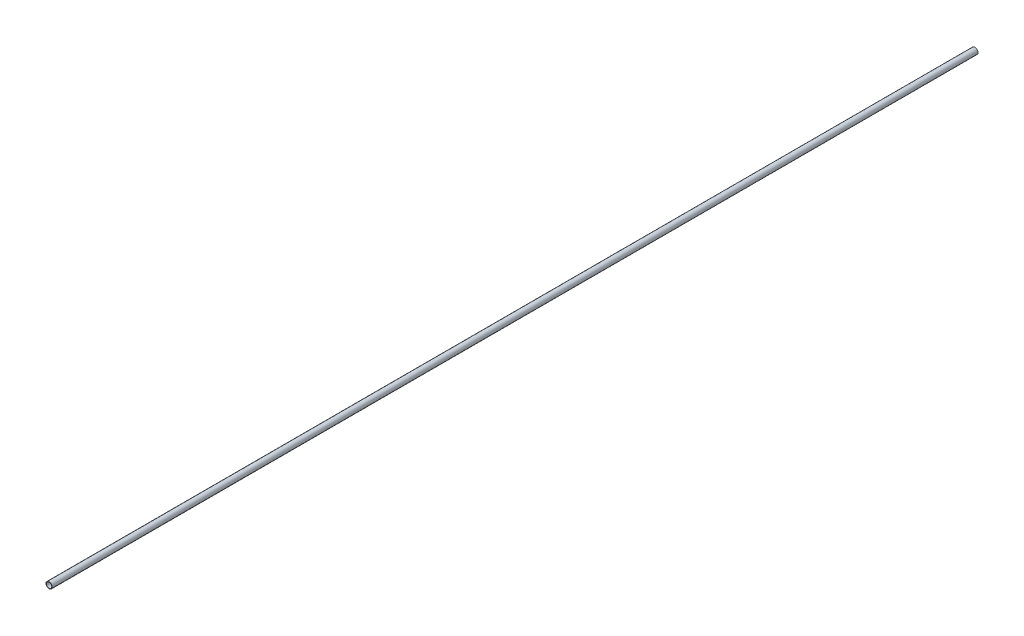
from build123d import *

# Parameters (mm, degrees)
SKETCH1_R           = 4
SKETCH1_R_2         = 3.5
BOSS_EXTRUDE1_DEPTH = 1200


with BuildPart() as part:
    # Sketch1 → Boss-Extrude1 (new body)
    with BuildSketch(Plane.XY):
        Circle(SKETCH1_R)
        Circle(SKETCH1_R_2, mode=Mode.SUBTRACT)
    extrude(amount=BOSS_EXTRUDE1_DEPTH)


solid = part.part
